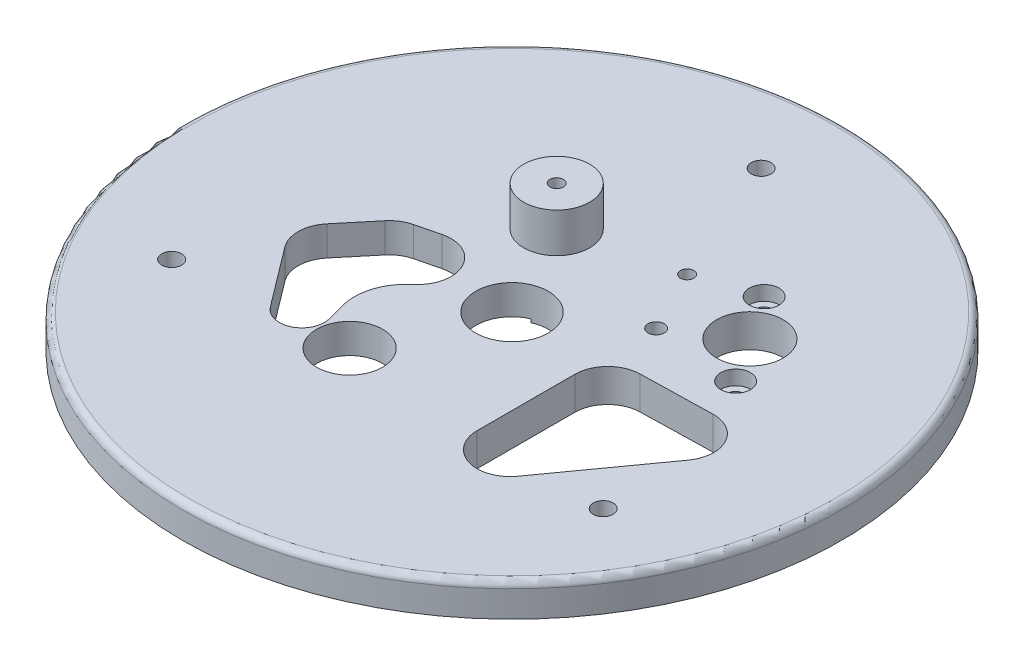
from build123d import *

# Parameters (mm, degrees)
SKETCH1_R                = 50
SKETCH1_R_2              = 5
BOSS_EXTRUDE1_DEPTH      = 5
SKETCH2_R                = 1.2
SKETCH2_R_2              = 1.225
SKETCH2_R_3              = 5.05
SKETCH2_R_4              = 1.015
CUT_EXTRUDE1_DEPTH       = 10
SKETCH5_R                = 5
SKETCH5_R_2              = 1.015
BOSS_EXTRUDE2_DEPTH      = 6
SKETCH9_R                = 2.357259082
BOSS_EXTRUDE4_DEPTH      = 1
FILLET1_R                = 1
SKETCH10_R               = 1.5
CUT_EXTRUDE3_DEPTH       = 2.2
CUT_EXTRUDE3_DEPTH_BACK  = 16
CUT_EXTRUDE6_DEPTH       = 0.5
CUT_EXTRUDE7_DEPTH       = 10
CUT_EXTRUDE9_DEPTH       = 10
CUT_EXTRUDE9_DEPTH_BACK  = 10
SKETCH17_R               = 5.5
CUT_EXTRUDE10_DEPTH      = 10
CUT_EXTRUDE10_DEPTH_BACK = 10
SKETCH18_R               = 2.25
CUT_EXTRUDE11_DEPTH      = 2.2


with BuildPart() as part:
    # Sketch1 → Boss-Extrude1 (new body)
    with BuildSketch(Plane(origin=(0, 0, 0), x_dir=(1, 0, 0), z_dir=(0, 1, 0))):
        Circle(SKETCH1_R)
        with Locations((-7.573934673, -17.06033615)):
            Circle(SKETCH1_R_2, mode=Mode.SUBTRACT)
    extrude(amount=BOSS_EXTRUDE1_DEPTH)

    # Sketch2 → Cut-Extrude1 (cut)
    with BuildSketch(Plane(origin=(0, 5, 0), x_dir=(1, 0, 0), z_dir=(0, 1, 0))):
        with Locations((26.030814012, 7.899159566)):
            Circle(SKETCH2_R)
        with Locations((17.087578103, 21.16635714)):
            Circle(SKETCH2_R)
        with Locations((13.062426036, 8.805202225)):
            Circle(SKETCH2_R_2)
        with Locations((21.559196058, 14.532758353)):
            Circle(SKETCH2_R_3)
        with Locations((8.320757608, 18.248434254)):
            Circle(SKETCH2_R_4)
    extrude(amount=-CUT_EXTRUDE1_DEPTH, mode=Mode.SUBTRACT)

    # Sketch5 → Boss-Extrude2 (add)
    with BuildSketch(Plane(origin=(0, 5, 0), x_dir=(1, 0, 0), z_dir=(0, 1, 0))):
        with Locations((-7.55311225, 14.331451264)):
            Circle(SKETCH5_R)
        with Locations((-7.55311225, 14.331451264)):
            Circle(SKETCH5_R_2, mode=Mode.SUBTRACT)
    extrude(amount=BOSS_EXTRUDE2_DEPTH)

    # Sketch9 → Boss-Extrude4 (add)
    with BuildSketch(Plane.XZ):
        with Locations((8.320757608, -18.248434254)):
            Circle(SKETCH9_R)
    extrude(amount=-BOSS_EXTRUDE4_DEPTH)

    # Fillet1
    fillet1_edges = [part.edges().sort_by_distance(p)[0] for p in [
        (-50, 5, 0),
    ]]
    fillet(fillet1_edges, radius=FILLET1_R)

    # Sketch10 → Cut-Extrude3 (cut, two sides)
    with BuildSketch(Plane(origin=(0, 5, 0), x_dir=(1, 0, 0), z_dir=(0, 1, 0))) as cut_extrude3_sk:
        with Locations((0, 37.8)):
            Circle(SKETCH10_R)
        with Locations((-32.735760263, -18.9)):
            Circle(SKETCH10_R)
        with Locations((32.735760263, -18.9)):
            Circle(SKETCH10_R)
    extrude(amount=CUT_EXTRUDE3_DEPTH, mode=Mode.SUBTRACT)
    extrude(cut_extrude3_sk.sketch, amount=-CUT_EXTRUDE3_DEPTH_BACK, mode=Mode.SUBTRACT)

    # Sketch12 → Cut-Extrude6 (cut)
    with BuildSketch(Plane.XZ):
        with BuildLine():
            Line((-21.313834783, 24.76213107), (-34.538834783, 1.855759139))
            ThreePointArc((-34.538834783, 1.855759139), (-35.038336896, -1.938336086), (-32.708707764, -4.974367879))
            Line((-32.708707764, -4.974367879), (-14.089161583, -15.724367879))
            ThreePointArc((-14.089161583, -15.724367879), (-10.295066357, -16.223869992), (-7.259034564, -13.894240861))
            Line((-7.259034564, -13.894240861), (5.965965436, 9.01213107))
            ThreePointArc((5.965965436, 9.01213107), (0.201065327, 30.527031179), (-21.313834783, 24.76213107))
        make_face()
    extrude(amount=-CUT_EXTRUDE6_DEPTH, mode=Mode.SUBTRACT)

    # Sketch13 → Cut-Extrude7 (cut)
    with BuildSketch(Plane(origin=(0, 5, 0), x_dir=(1, 0, 0), z_dir=(0, 1, 0))):
        with BuildLine():
            Line((32.816836472, -6.07169605), (21.984996749, -21.138640776))
            ThreePointArc((21.984996749, -21.138640776), (16.391033491, -22.978825985), (12.925236211, -18.21784334))
            Line((12.925236211, -18.21784334), (12.931687147, -3.407234286))
            ThreePointArc((12.931687147, -3.407234286), (14.35531099, 0.084802692), (17.813324255, 1.589186743))
            Line((17.813324255, 1.589186743), (28.638713042, 1.845522414))
            ThreePointArc((28.638713042, 1.845522414), (33.179093412, -0.819461796), (32.816836472, -6.07169605))
        make_face()
    extrude(amount=-CUT_EXTRUDE7_DEPTH, mode=Mode.SUBTRACT)

    # Sketch16 → Cut-Extrude9 (cut, two sides)
    with BuildSketch(Plane.XZ.offset(-0.5)) as cut_extrude9_sk:
        with BuildLine():
            Line((-12.984156175, 14.705600426), (-13.719701132, 11.95882482))
            ThreePointArc((-13.719701132, 11.95882482), (-13.693758532, 7.802544191), (-11.54963643, 4.241914739))
            Line((-11.54963643, 4.241914739), (-10.842839117, 3.568938111))
            ThreePointArc((-10.842839117, 3.568938111), (-9.907482144, -2.457917187), (-15.493944375, -4.905225341))
            Line((-15.493944375, -4.905225341), (-19.004093622, -4.034917019))
            ThreePointArc((-19.004093622, -4.034917019), (-20.457115896, -3.417911536), (-21.645362284, -2.3786618))
            Line((-21.645362284, -2.3786618), (-25.653320737, 2.441392154))
            ThreePointArc((-25.653320737, 2.441392154), (-26.807383132, 5.519886283), (-25.80025353, 8.649531003))
            Line((-25.80025353, 8.649531003), (-19.012059198, 17.647148968))
            ThreePointArc((-19.012059198, 17.647148968), (-14.786139745, 18.659973084), (-12.984156175, 14.705600426))
        make_face()
    extrude(amount=CUT_EXTRUDE9_DEPTH, mode=Mode.SUBTRACT)
    extrude(cut_extrude9_sk.sketch, amount=-CUT_EXTRUDE9_DEPTH_BACK, mode=Mode.SUBTRACT)

    # Sketch17 → Cut-Extrude10 (cut, two sides)
    with BuildSketch(Plane.XZ.offset(-0.5)) as cut_extrude10_sk:
        Circle(SKETCH17_R)
    extrude(amount=CUT_EXTRUDE10_DEPTH, mode=Mode.SUBTRACT)
    extrude(cut_extrude10_sk.sketch, amount=-CUT_EXTRUDE10_DEPTH_BACK, mode=Mode.SUBTRACT)

    # Sketch18 → Cut-Extrude11 (cut)
    with BuildSketch(Plane(origin=(0, 5, 0), x_dir=(1, 0, 0), z_dir=(0, 1, 0))):
        with Locations((17.087578103, 21.16635714)):
            Circle(SKETCH18_R)
        with Locations((26.030814012, 7.899159566)):
            Circle(SKETCH18_R)
    extrude(amount=-CUT_EXTRUDE11_DEPTH, mode=Mode.SUBTRACT)


solid = part.part
